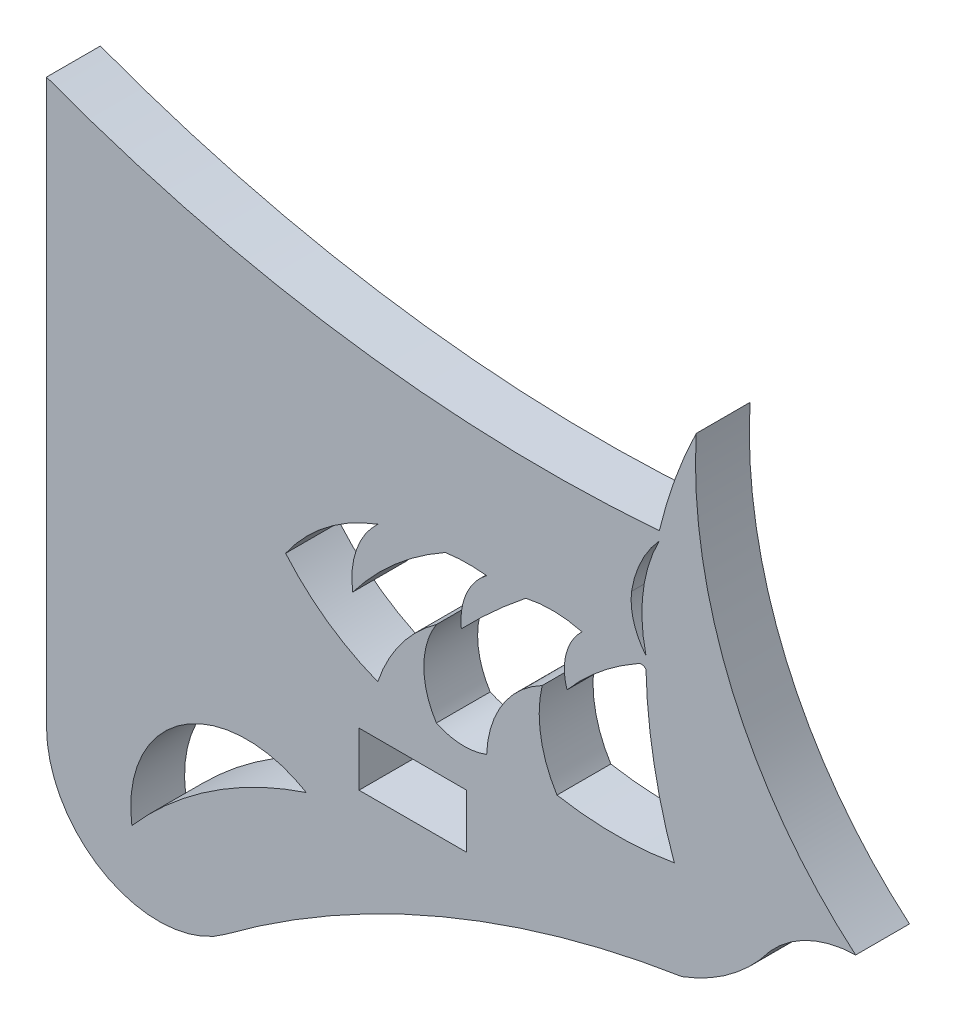
from build123d import *

# Parameters (mm, degrees)
SKETCH1_W           = 3.048
SKETCH1_H           = 1.524
BOSS_EXTRUDE1_DEPTH = 1.524
FILLET4_R           = 3.175


with BuildPart() as part:
    # Sketch1 → Boss-Extrude1 (new body)
    with BuildSketch(Plane.XY):
        with BuildLine():
            Line((0.680153889, -6.129418594), (0.680153889, 11.540681963))
            ThreePointArc((0.680153889, 11.540681963), (9.222616512, 9.36144264), (18.034529819, 9.091376803))
            ThreePointArc((18.034529819, 9.091376803), (18.476514137, 10.575327988), (19.079546917, 12.001446047))
            ThreePointArc((19.079546917, 12.001446047), (20.097392283, 6.202497031), (23.594187572, 1.465806036))
            ThreePointArc((23.594187572, 1.465806036), (22.264781917, 1.159048918), (21.169318906, 0.345796118))
            ThreePointArc((21.169318906, 0.345796118), (20.057462236, -0.769306292), (18.675392755, -1.524))
            ThreePointArc((18.675392755, -1.524), (10.681603645, -3.986495409), (3.71145902, -8.610523078))
            ThreePointArc((3.71145902, -8.610523078), (1.563251963, -8.142798296), (0.680153889, -6.129418594))
        make_face()
        with Locations((11.054430571, -0.762)):
            Rectangle(SKETCH1_W, SKETCH1_H, mode=Mode.SUBTRACT)
        with BuildLine():
            ThreePointArc((18.457205049, 1.159048918), (16.796602855, 1.012131062), (15.13600066, 1.159048918))
            ThreePointArc((15.13600066, 1.159048918), (14.678205729, 2.355037825), (14.715312916, 3.635111542))
            ThreePointArc((14.715312916, 3.635111542), (13.593992305, 2.610148755), (13.144305869, 1.159048918))
            ThreePointArc((13.144305869, 1.159048918), (12.426226698, 1.043141082), (11.720524566, 1.219370545))
            ThreePointArc((11.720524566, 1.219370545), (11.364676413, 2.427241044), (11.720524566, 3.635111542))
            ThreePointArc((11.720524566, 3.635111542), (10.712351561, 2.650528395), (10.061249405, 1.400775314))
            ThreePointArc((10.061249405, 1.400775314), (8.64082558, 2.160669947), (7.450155331, 3.245726654))
            ThreePointArc((7.450155331, 3.245726654), (8.601081625, 4.454929507), (10.061249405, 5.264072837))
            ThreePointArc((10.061249405, 5.264072837), (9.457771061, 4.34236946), (9.352425063, 3.245726654))
            ThreePointArc((9.352425063, 3.245726654), (10.543430802, 4.522443251), (11.971709271, 5.526694491))
            ThreePointArc((11.971709271, 5.526694491), (12.557411502, 5.573473862), (13.144305869, 5.545359518))
            ThreePointArc((13.144305869, 5.545359518), (12.566006589, 4.808091463), (12.426226698, 3.881562551))
            ThreePointArc((12.426226698, 3.881562551), (13.312490945, 4.743692313), (14.253799466, 5.545359518))
            ThreePointArc((14.253799466, 5.545359518), (15.051720121, 5.625849498), (15.84620994, 5.516570329))
            ThreePointArc((15.84620994, 5.516570329), (15.396051863, 4.760868409), (15.419480332, 3.881562551))
            ThreePointArc((15.419480332, 3.881562551), (16.340692115, 4.785475695), (17.404266633, 5.516570329))
            ThreePointArc((17.404266633, 5.516570329), (17.532648387, 5.563352566), (17.656087794, 5.504759346))
            ThreePointArc((17.656087794, 5.504759346), (17.884238381, 3.300121283), (18.457205049, 1.159048918))
        make_face(mode=Mode.SUBTRACT)
        with BuildLine():
            ThreePointArc((17.656087794, 5.840129035), (17.574660077, 7.375234106), (18.034529819, 8.84210079))
            ThreePointArc((18.034529819, 8.84210079), (17.521152532, 8.084430816), (17.246705878, 7.211333419))
            ThreePointArc((17.246705878, 7.211333419), (17.311898149, 6.484082994), (17.656087794, 5.840129035))
        make_face(mode=Mode.SUBTRACT)
        with BuildLine():
            ThreePointArc((8.037489597, -2.327562697), (5.34711842, -3.636841183), (3.096001374, -5.607825523))
            ThreePointArc((3.096001374, -5.607825523), (4.535873462, -2.414756972), (8.037489597, -2.327562697))
        make_face(mode=Mode.SUBTRACT)
    extrude(amount=BOSS_EXTRUDE1_DEPTH)

    # Fillet4
    fillet4_edges = [part.edges().sort_by_distance(p)[0] for p in [
        (3.71145902, -8.610523078, 0.762),
    ]]
    fillet(fillet4_edges, radius=FILLET4_R)


solid = part.part
